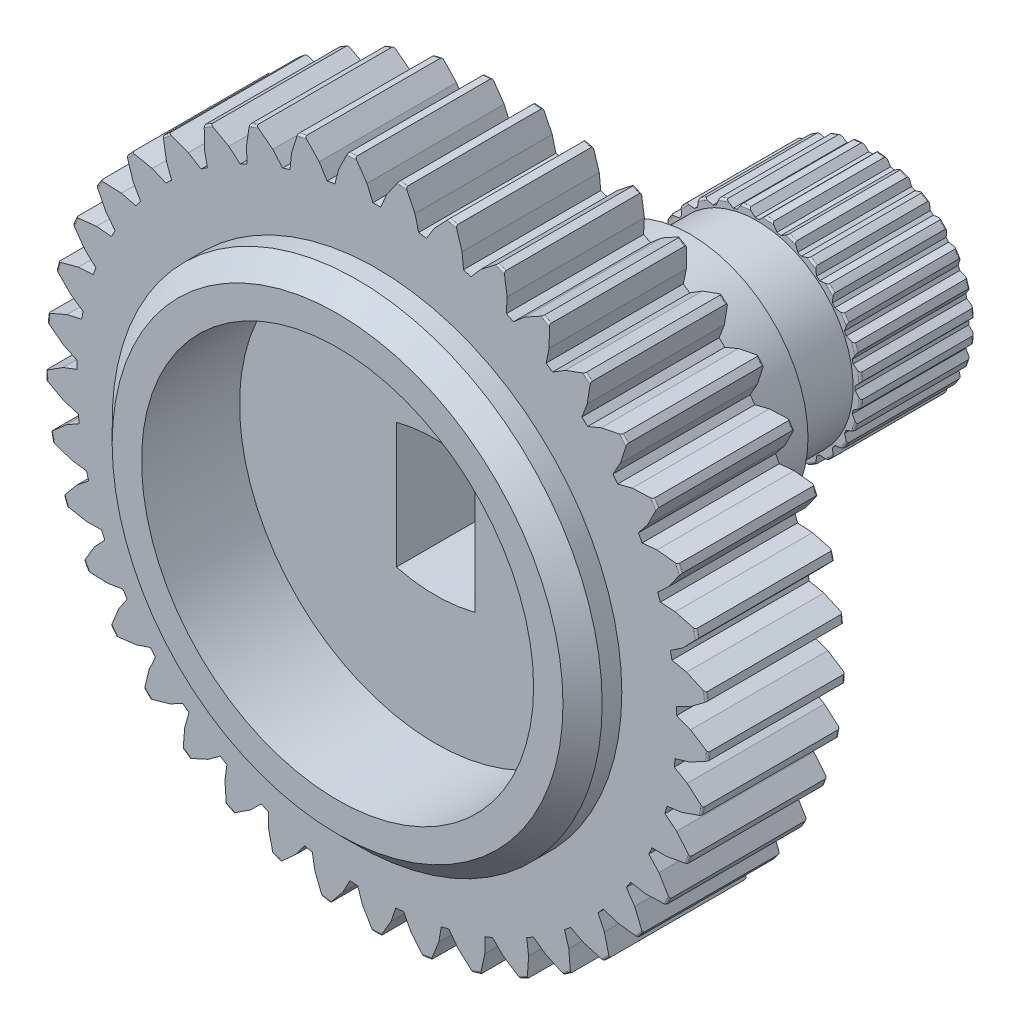
from build123d import *

# Parameters (mm, degrees)
CROQUIS1_R              = 8.45
SALIENTE_EXTRUIR1_DEPTH = 3.5
REDONDEO1_R             = 0.05
CROQUIS2_R              = 6.25
SALIENTE_EXTRUIR2_DEPTH = 1
CHAFL_N1_SIZE           = 0.5
CORTAR_EXTRUIR1_DEPTH   = 3.8
MATRIZC1_COUNT          = 41
CROQUIS3_3_R            = 3.5
SALIENTE_EXTRUIR3_DEPTH = 1.8
CROQUIS5_R              = 3
SALIENTE_EXTRUIR4_DEPTH = 2.7
CROQUIS6_R              = 2.65
SALIENTE_EXTRUIR5_DEPTH = 4.6
CROQUIS8_OUTSIDE_W      = 24.39
CROQUIS8_OUTSIDE_H      = 24.378
CROQUIS8_OUTSIDE_R      = 2.45
CORTAR_EXTRUIR3_DEPTH   = 1.7
REDONDEO4_R             = 0.05
CORTAR_EXTRUIR2_DEPTH   = 2.9
MATRIZC2_COUNT          = 28
CROQUIS9_R              = 0.7
CORTAR_EXTRUIR4_DEPTH   = 1
CROQUIS10_R             = 1.5
CORTAR_EXTRUIR5_DEPTH   = 4
CHAFL_N2_SIZE           = 0.3
CROQUIS11_R             = 5
CORTAR_EXTRUIR6_DEPTH   = 2.5
CORTAR_EXTRUIR7_DEPTH   = 3


with BuildPart() as part:
    # Croquis1 → Saliente-Extruir1 (new body)
    with BuildSketch(Plane.XY):
        Circle(CROQUIS1_R)
    extrude(amount=SALIENTE_EXTRUIR1_DEPTH)

    # Redondeo1
    redondeo1_edges = [part.edges().sort_by_distance(p)[0] for p in [
        (-8.45, 0, 0),
        (-8.45, 0, 3.5),
    ]]
    fillet(redondeo1_edges, radius=REDONDEO1_R)

    # Croquis2 → Saliente-Extruir2 (add)
    with BuildSketch(Plane.XY.offset(3.5)):
        Circle(CROQUIS2_R)
    extrude(amount=SALIENTE_EXTRUIR2_DEPTH)

    # Chaflán1
    chafl_n1_edges = [part.edges().sort_by_distance(p)[0] for p in [
        (-6.25, 0, 4.5),
    ]]
    chamfer(chafl_n1_edges, length=CHAFL_N1_SIZE)

    # Croquis3 → Cortar-Extruir1 (cut)
    with BuildSketch(Plane(origin=(0, 0, 0), x_dir=(-1, 0, 0), z_dir=(0, 0, -1))):
        with BuildLine():
            ThreePointArc((-0.1, 7.649346377), (0, 7.65), (0.1, 7.649346377))
            Line((0.1, 7.649346377), (0.25, 8))
            Line((0.25, 8), (0.55, 8.432081594))
            Line((0.55, 8.432081594), (0.55, 8.6))
            Line((0.55, 8.6), (-0.55, 8.6))
            Line((-0.55, 8.6), (-0.55, 8.432081594))
            Line((-0.55, 8.432081594), (-0.25, 8))
            Line((-0.25, 8), (-0.1, 7.649346377))
        make_face()
    cortar_extruir1 = extrude(amount=-CORTAR_EXTRUIR1_DEPTH, mode=Mode.SUBTRACT)

    # MatrizC1: Cortar-Extruir1 ×41 about axis
    matrizc1_axis = Axis((0, 0, 3.5), (0, 0, -1))
    for i in range(1, MATRIZC1_COUNT):
        add(cortar_extruir1.rotate(matrizc1_axis, i * 360 / MATRIZC1_COUNT), mode=Mode.SUBTRACT)

    # Croquis3_3 → Saliente-Extruir3 (add)
    with BuildSketch(Plane(origin=(0, 0, 0), x_dir=(-1, 0, 0), z_dir=(0, 0, -1))):
        Circle(CROQUIS3_3_R)
    extrude(amount=SALIENTE_EXTRUIR3_DEPTH)

    # Croquis5 → Saliente-Extruir4 (add)
    with BuildSketch(Plane(origin=(0, 0, -1.8), x_dir=(-1, 0, 0), z_dir=(0, 0, -1))):
        Circle(CROQUIS5_R)
    extrude(amount=SALIENTE_EXTRUIR4_DEPTH)

    # Croquis6 → Saliente-Extruir5 (add)
    with BuildSketch(Plane(origin=(0, 0, -4.5), x_dir=(-1, 0, 0), z_dir=(0, 0, -1))):
        Circle(CROQUIS6_R)
    extrude(amount=SALIENTE_EXTRUIR5_DEPTH)

    # Croquis8 outside → Cortar-Extruir3 (cut)
    with BuildSketch(Plane(origin=(0, 0, -4.5), x_dir=(-1, 0, 0), z_dir=(0, 0, -1))):
        with Locations((0, -0.009)):
            Rectangle(CROQUIS8_OUTSIDE_W, CROQUIS8_OUTSIDE_H)
        Circle(CROQUIS8_OUTSIDE_R, mode=Mode.SUBTRACT)
    extrude(amount=CORTAR_EXTRUIR3_DEPTH, mode=Mode.SUBTRACT)

    # Redondeo4
    redondeo4_edges = [part.edges().sort_by_distance(p)[0] for p in [
        (2.65, 0, -9.1),
        (2.65, 0, -6.2),
    ]]
    fillet(redondeo4_edges, radius=REDONDEO4_R)

    # Croquis7 → Cortar-Extruir2 (cut)
    with BuildSketch(Plane(origin=(0, 0, -9.1), x_dir=(-1, 0, 0), z_dir=(0, 0, -1))):
        with BuildLine():
            Line((0.2, 2.642442052), (0.2, 2.7))
            Line((0.2, 2.7), (-0.2, 2.7))
            Line((-0.2, 2.7), (-0.2, 2.642442052))
            Line((-0.2, 2.642442052), (-0.12, 2.566206264))
            Line((-0.12, 2.566206264), (-0.05, 2.49949995))
            ThreePointArc((-0.05, 2.49949995), (0, 2.5), (0.05, 2.49949995))
            Line((0.05, 2.49949995), (0.12, 2.566206264))
            Line((0.12, 2.566206264), (0.2, 2.642442052))
        make_face()
    cortar_extruir2 = extrude(amount=-CORTAR_EXTRUIR2_DEPTH, mode=Mode.SUBTRACT)

    # MatrizC2: Cortar-Extruir2 ×28 about axis
    matrizc2_axis = Axis((0, 0, -9.1), (0, 0, 1))
    for i in range(1, MATRIZC2_COUNT):
        add(cortar_extruir2.rotate(matrizc2_axis, i * 360 / MATRIZC2_COUNT), mode=Mode.SUBTRACT)

    # Croquis9 → Cortar-Extruir4 (cut)
    with BuildSketch(Plane(origin=(0, 0, 0), x_dir=(-1, 0, 0), z_dir=(0, 0, -1))):
        with Locations((0, 6.3)):
            Circle(CROQUIS9_R)
    extrude(amount=-CORTAR_EXTRUIR4_DEPTH, mode=Mode.SUBTRACT)

    # Croquis10 → Cortar-Extruir5 (cut)
    with BuildSketch(Plane(origin=(0, 0, -9.1), x_dir=(-1, 0, 0), z_dir=(0, 0, -1))):
        Circle(CROQUIS10_R)
    extrude(amount=-CORTAR_EXTRUIR5_DEPTH, mode=Mode.SUBTRACT)

    # Chaflán2
    chafl_n2_edges = [part.edges().sort_by_distance(p)[0] for p in [
        (1.5, 0, -9.1),
    ]]
    chamfer(chafl_n2_edges, length=CHAFL_N2_SIZE)

    # Croquis11 → Cortar-Extruir6 (cut)
    with BuildSketch(Plane.XY.offset(4.5)):
        Circle(CROQUIS11_R)
    extrude(amount=-CORTAR_EXTRUIR6_DEPTH, mode=Mode.SUBTRACT)

    # Croquis12 → Cortar-Extruir7 (cut)
    with BuildSketch(Plane.XY.offset(2)):
        with BuildLine():
            Line((1, 1.6), (1, -1.6))
            ThreePointArc((1, -1.6), (0, -1.727016654), (-1, -1.6))
            Line((-1, -1.6), (-1, 1.6))
            ThreePointArc((-1, 1.6), (0, 1.727016654), (1, 1.6))
        make_face()
    extrude(amount=-CORTAR_EXTRUIR7_DEPTH, mode=Mode.SUBTRACT)


solid = part.part
